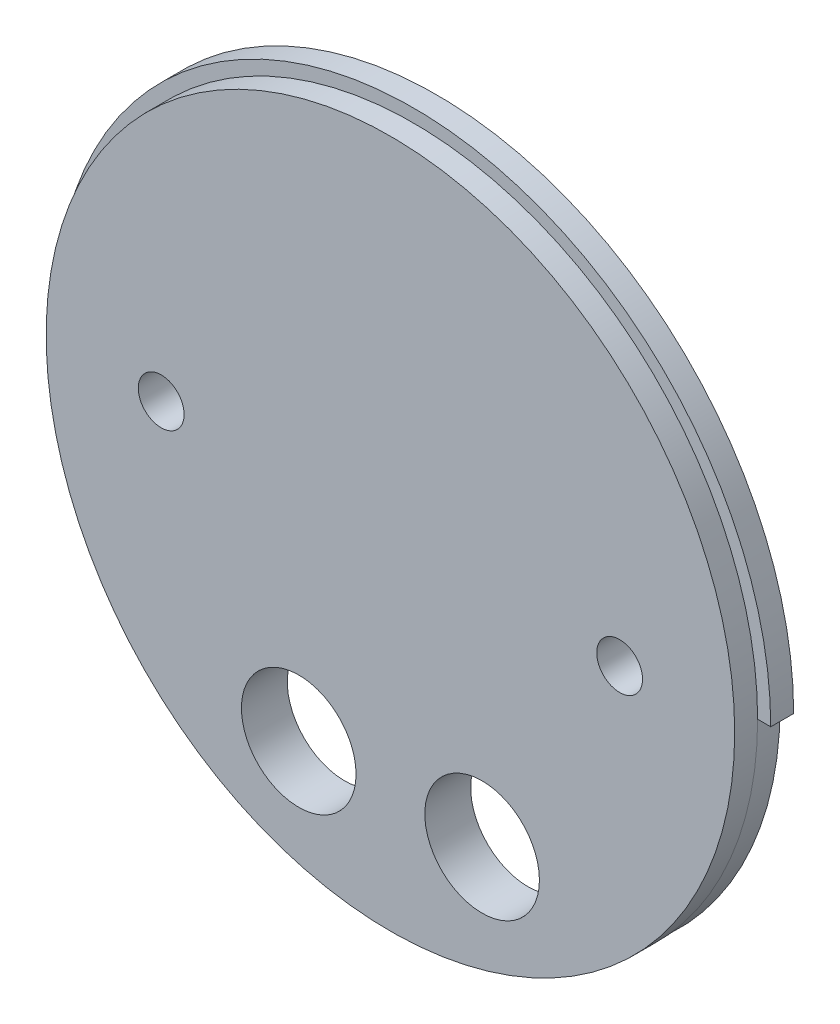
from build123d import *

# Parameters (mm, degrees)
SKETCH1_R           = 49.5046
BOSS_EXTRUDE1_DEPTH = 3.175
SKETCH2_R           = 47.6885
BOSS_EXTRUDE2_DEPTH = 3.175
SKETCH3_R           = 3.175
SKETCH3_R_2         = 7.9375
CUT_EXTRUDE1_DEPTH  = 7.35
CUT_EXTRUDE2_DEPTH  = 4.175


with BuildPart() as part:
    # Sketch1 → Boss-Extrude1 (new body)
    with BuildSketch(Plane.XY):
        Circle(SKETCH1_R)
    extrude(amount=BOSS_EXTRUDE1_DEPTH)

    # Sketch2 → Boss-Extrude2 (add)
    with BuildSketch(Plane.XY.offset(3.175)):
        Circle(SKETCH2_R)
    extrude(amount=BOSS_EXTRUDE2_DEPTH)

    # Sketch3 → Cut-Extrude1 (cut, through all)
    with BuildSketch(Plane.XY.offset(6.35)):
        with Locations((-31.75, 0)):
            Circle(SKETCH3_R)
        with Locations((31.75, 0)):
            Circle(SKETCH3_R)
        with Locations((-12.7, -31.235352443)):
            Circle(SKETCH3_R_2)
        with Locations((12.7, -31.235352443)):
            Circle(SKETCH3_R_2)
    extrude(amount=-CUT_EXTRUDE1_DEPTH, mode=Mode.SUBTRACT)

    # Sketch4 → Cut-Extrude2 (cut, through all)
    with BuildSketch(Plane.XY.offset(3.175)):
        with BuildLine():
            Line((-50.165, 0), (-47.625, 0))
            ThreePointArc((-47.625, 0), (0, -47.625), (47.625, 0))
            Line((47.625, 0), (50.165, 0))
            ThreePointArc((50.165, 0), (0, -50.165), (-50.165, 0))
        make_face()
    extrude(amount=-CUT_EXTRUDE2_DEPTH, mode=Mode.SUBTRACT)


solid = part.part
